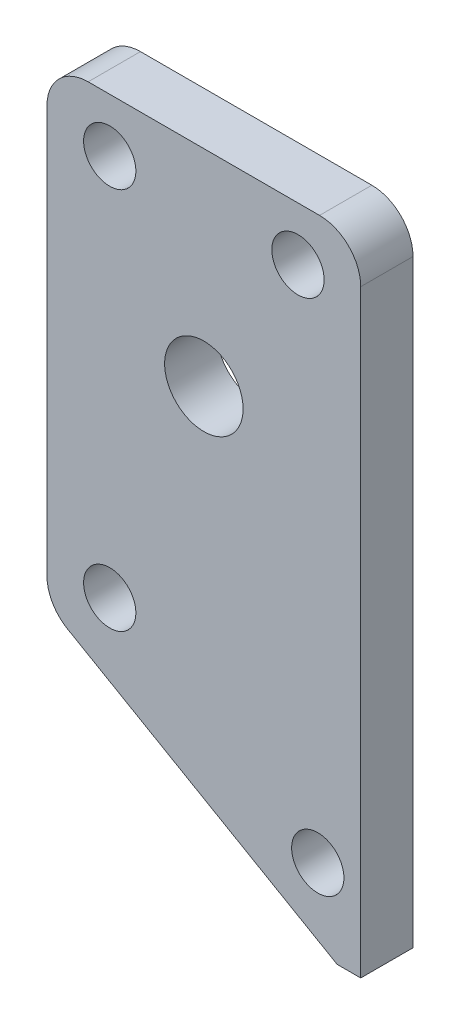
from build123d import *

# Parameters (mm, degrees)
SKETCH1_R           = 3.175
SKETCH1_R_2         = 4.7625
BOSS_EXTRUDE1_DEPTH = 6.35
FILLET1_R           = 5


with BuildPart() as part:
    # Sketch1 → Boss-Extrude1 (new body)
    with BuildSketch(Plane.XY):
        Polygon((16.184070214, -255.902577388), (-19.05, -235.560177465), (-19.05, -178.2), (19.05, -178.2), (19.05, -255.902577388), align=None)
        with Locations((13.834070214, -246.4)):
            Circle(SKETCH1_R, mode=Mode.SUBTRACT)
        with Locations((-11.43, -231.16)):
            Circle(SKETCH1_R, mode=Mode.SUBTRACT)
        with Locations((0, -203.2)):
            Circle(SKETCH1_R_2, mode=Mode.SUBTRACT)
        with Locations((-11.43, -184.7)):
            Circle(SKETCH1_R, mode=Mode.SUBTRACT)
        with Locations((11.43, -184.7)):
            Circle(SKETCH1_R, mode=Mode.SUBTRACT)
    extrude(amount=BOSS_EXTRUDE1_DEPTH)

    # Fillet1
    fillet1_edges = [part.edges().sort_by_distance(p)[0] for p in [
        (-19.05, -235.560177465, 3.175),
        (-19.05, -178.2, 3.175),
        (19.05, -178.2, 3.175),
    ]]
    fillet(fillet1_edges, radius=FILLET1_R)


solid = part.part
